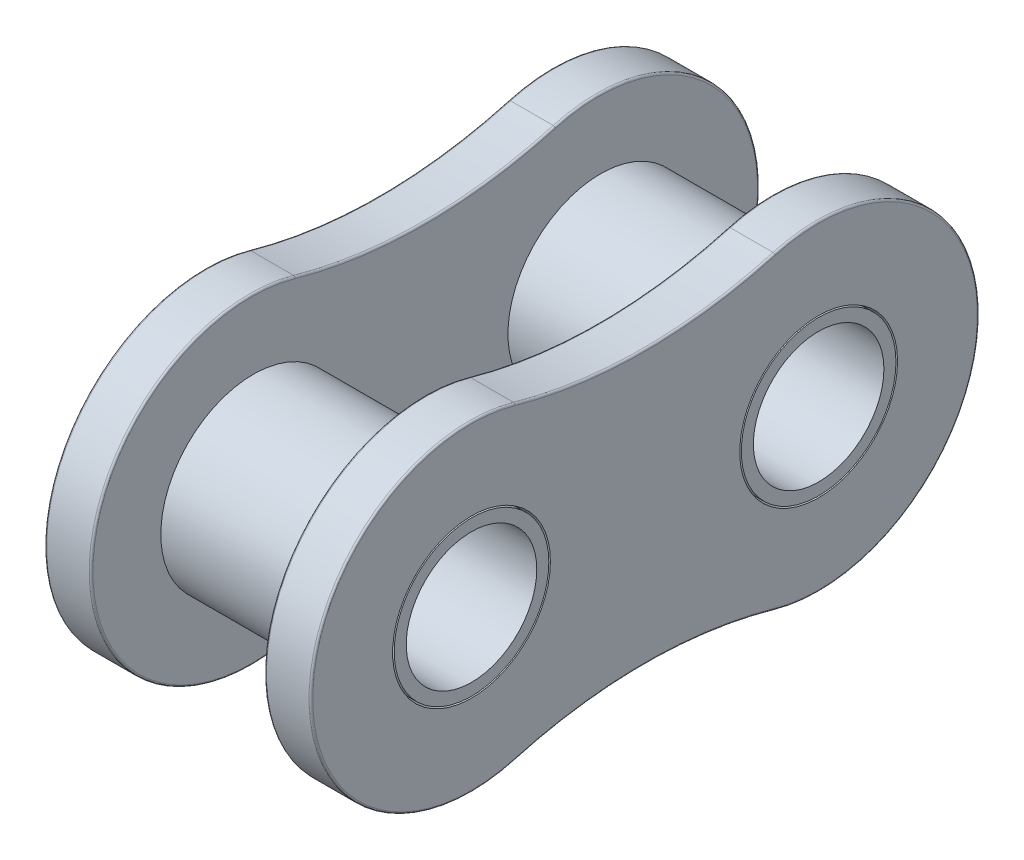
from build123d import *

# Parameters (mm, degrees)
BOSS_EXTRUDE1_START   = 2.38125
SKETCH3_R             = 2.16535
BOSS_EXTRUDE1_DEPTH   = 1.27
FILLET1_R             = 0.0508
SKETCH4_R             = 2.54
SKETCH4_R_2           = 1.7907
BOSS_EXTRUDE2_DEPTH   = 2.333625
BOSS_EXTRUDE2_2_DEPTH = 2.333625
SKETCH5_R             = 2.122043
SKETCH5_R_2           = 1.7907
BOSS_EXTRUDE3_DEPTH   = 1.317625
SKETCH6_R             = 2.122043
SKETCH6_R_2           = 1.7907
BOSS_EXTRUDE4_DEPTH   = 1.317625


with BuildPart() as part:
    # Sketch3 → Boss-Extrude1 (new body)
    with BuildSketch(Plane(origin=(0, 0, 0), x_dir=(0, 0, -1), z_dir=(1, 0, 0)).offset(BOSS_EXTRUDE1_START)):
        with BuildLine():
            ThreePointArc((-3.562267566, 4.240307738), (-9.1694, 0), (-3.562267566, -4.240307738))
            ThreePointArc((-3.562267566, -4.240307738), (0, -3.745865), (3.562267566, -4.240307738))
            ThreePointArc((3.562267566, -4.240307738), (9.1694, 0), (3.562267566, 4.240307738))
            ThreePointArc((3.562267566, 4.240307738), (0, 3.745865), (-3.562267566, 4.240307738))
        make_face()
        with Locations((-4.7625, 0)):
            Circle(SKETCH3_R, mode=Mode.SUBTRACT)
        with Locations((4.7625, 0)):
            Circle(SKETCH3_R, mode=Mode.SUBTRACT)
    extrude(amount=BOSS_EXTRUDE1_DEPTH)

    # Fillet1
    fillet1_edges = [part.edges().sort_by_distance(p)[0] for p in [
        (2.38125, -3.745865, 0),
        (2.38125, 0, -9.1694),
        (2.38125, 3.745865, 0),
        (3.65125, 0, -9.1694),
        (3.65125, -3.745865, 0),
        (3.65125, 0, 9.1694),
        (3.65125, 3.745865, 0),
        (2.38125, 0, 9.1694),
    ]]
    fillet(fillet1_edges, radius=FILLET1_R)


with BuildPart() as body_2:
    # Mirror1: mirrored copy
    add(part.part.mirror(Plane(origin=(0, 0, 0), x_dir=(0, 0, 1), z_dir=(1, 0, 0))))


with BuildPart() as body_3:
    # Sketch4 → Boss-Extrude2 (new body, symmetric)
    with BuildSketch(Plane(origin=(0, 0, 0), x_dir=(0, 0, -1), z_dir=(1, 0, 0))):
        with Locations((-4.7625, 0)):
            Circle(SKETCH4_R)
        with Locations((-4.7625, 0)):
            Circle(SKETCH4_R_2, mode=Mode.SUBTRACT)
    extrude(amount=BOSS_EXTRUDE2_DEPTH, both=True)


with BuildPart() as body_4:
    # Sketch4 → Boss-Extrude2 2 (new body, symmetric)
    with BuildSketch(Plane(origin=(0, 0, 0), x_dir=(0, 0, -1), z_dir=(1, 0, 0))):
        with Locations((4.7625, 0)):
            Circle(SKETCH4_R)
        with Locations((4.7625, 0)):
            Circle(SKETCH4_R_2, mode=Mode.SUBTRACT)
    extrude(amount=BOSS_EXTRUDE2_2_DEPTH, both=True)


with BuildPart() as body_5:
    # Sketch5 → Boss-Extrude3 (new body)
    with BuildSketch(Plane(origin=(2.333625, 0, 0), x_dir=(0, 0, -1), z_dir=(1, 0, 0))):
        with Locations((-4.7625, 0)):
            Circle(SKETCH5_R)
        with Locations((-4.7625, 0)):
            Circle(SKETCH5_R_2, mode=Mode.SUBTRACT)
    extrude(amount=BOSS_EXTRUDE3_DEPTH)


with BuildPart() as body_6:
    # Sketch6 → Boss-Extrude4 (new body)
    with BuildSketch(Plane(origin=(2.333625, 0, 0), x_dir=(0, 0, -1), z_dir=(1, 0, 0))):
        with Locations((4.7625, 0)):
            Circle(SKETCH6_R)
        with Locations((4.7625, 0)):
            Circle(SKETCH6_R_2, mode=Mode.SUBTRACT)
    extrude(amount=BOSS_EXTRUDE4_DEPTH)


with BuildPart() as body_7:
    # Mirror2: mirrored copy
    add(body_5.part.mirror(Plane(origin=(0, 0, 0), x_dir=(0, 0, 1), z_dir=(1, 0, 0))))


with BuildPart() as body_8:
    # Mirror2 2: mirrored copy
    add(body_6.part.mirror(Plane(origin=(0, 0, 0), x_dir=(0, 0, 1), z_dir=(1, 0, 0))))


with BuildPart() as body_3_1:
    add(body_3.part)

    # Combine1: union body 5, body 7
    add(body_5.part)
    add(body_7.part)


with BuildPart() as body_4_1:
    add(body_4.part)

    # Combine2: union body 6, body 8
    add(body_6.part)
    add(body_8.part)


solid = Compound([part.part, body_2.part, body_3_1.part, body_4_1.part])
